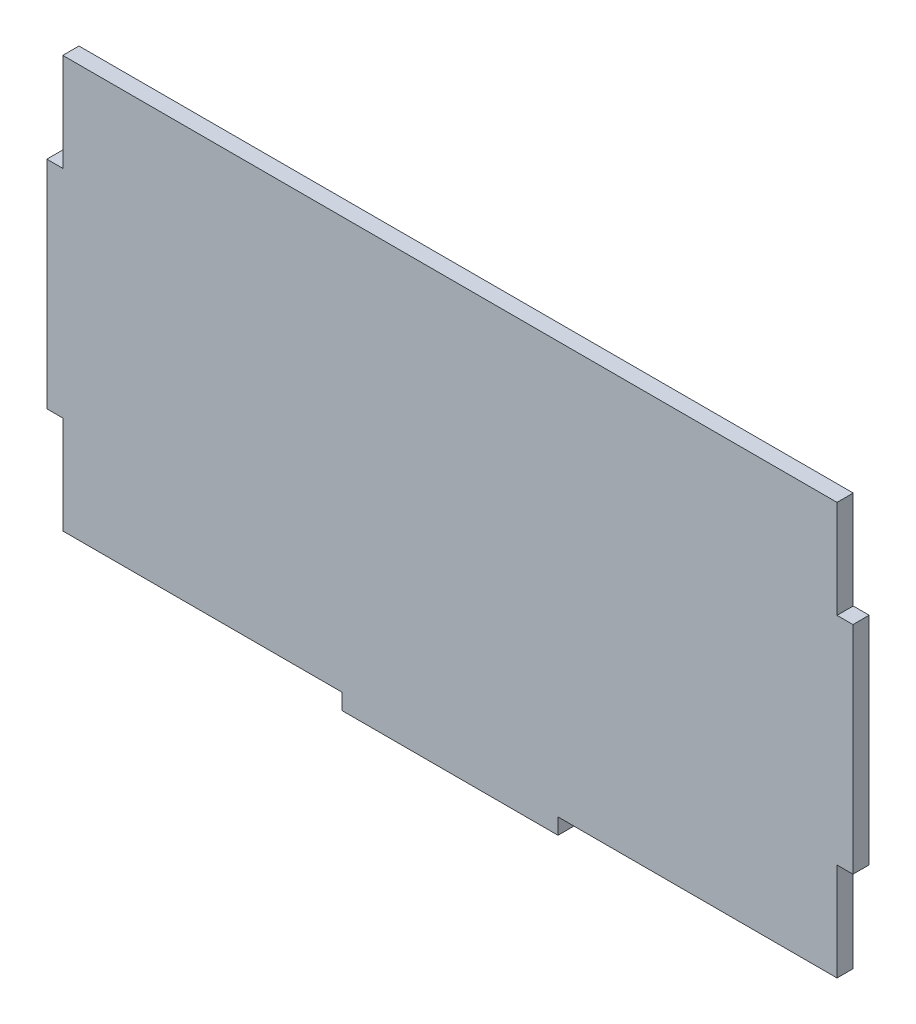
from build123d import *

# Parameters (mm, degrees)
SKETCH1_W           = 143.2306
SKETCH1_H           = 76.2
BOSS_EXTRUDE1_DEPTH = 1.4986
SKETCH2_W           = 2.9464
SKETCH2_H           = 40
SKETCH2_W_2         = 40
SKETCH2_H_2         = 2.9464
BOSS_EXTRUDE2_DEPTH = 2.9972


with BuildPart() as part:
    # Sketch1 → Boss-Extrude1 (new body, symmetric)
    with BuildSketch(Plane.XY):
        Rectangle(SKETCH1_W, SKETCH1_H)
    extrude(amount=BOSS_EXTRUDE1_DEPTH, both=True)

    # Sketch2 → Boss-Extrude2 (add, through all)
    with BuildSketch(Plane.XY.offset(1.4986)):
        with Locations((-73.0885, 0)):
            Rectangle(SKETCH2_W, SKETCH2_H)
        with Locations((0, -39.5732)):
            Rectangle(SKETCH2_W_2, SKETCH2_H_2)
        with Locations((73.0885, 0)):
            Rectangle(SKETCH2_W, SKETCH2_H)
    extrude(amount=-BOSS_EXTRUDE2_DEPTH)


solid = part.part
